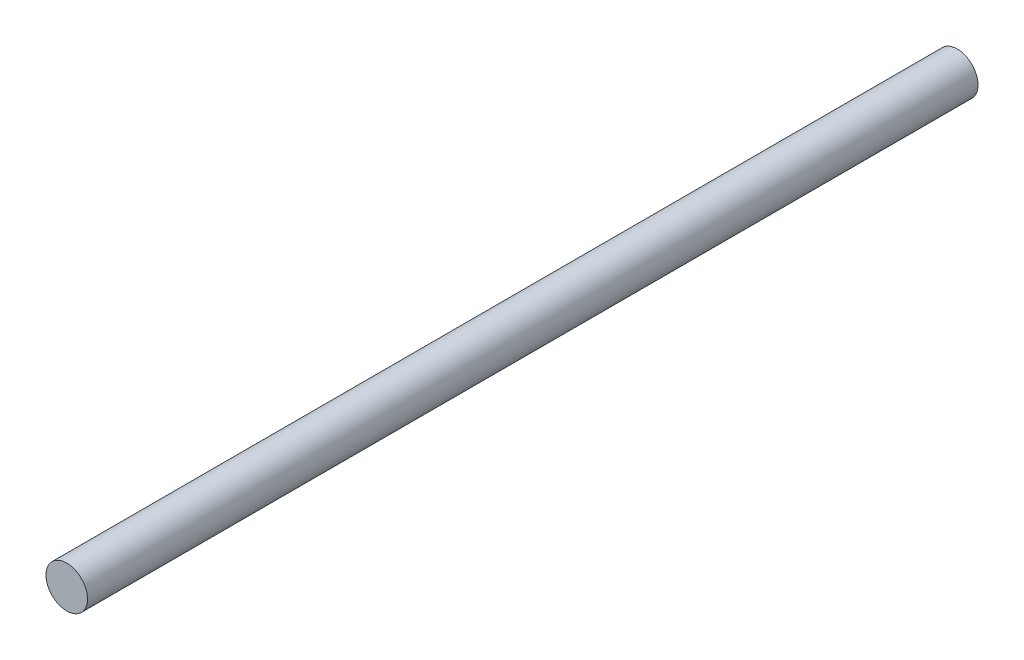
from build123d import *

# Parameters (mm, degrees)
SKETCH1_R           = 0.889
BOSS_EXTRUDE1_DEPTH = 38.1


with BuildPart() as part:
    # Sketch1 → Boss-Extrude1 (new body)
    with BuildSketch(Plane.XY):
        Circle(SKETCH1_R)
    extrude(amount=BOSS_EXTRUDE1_DEPTH)


solid = part.part
